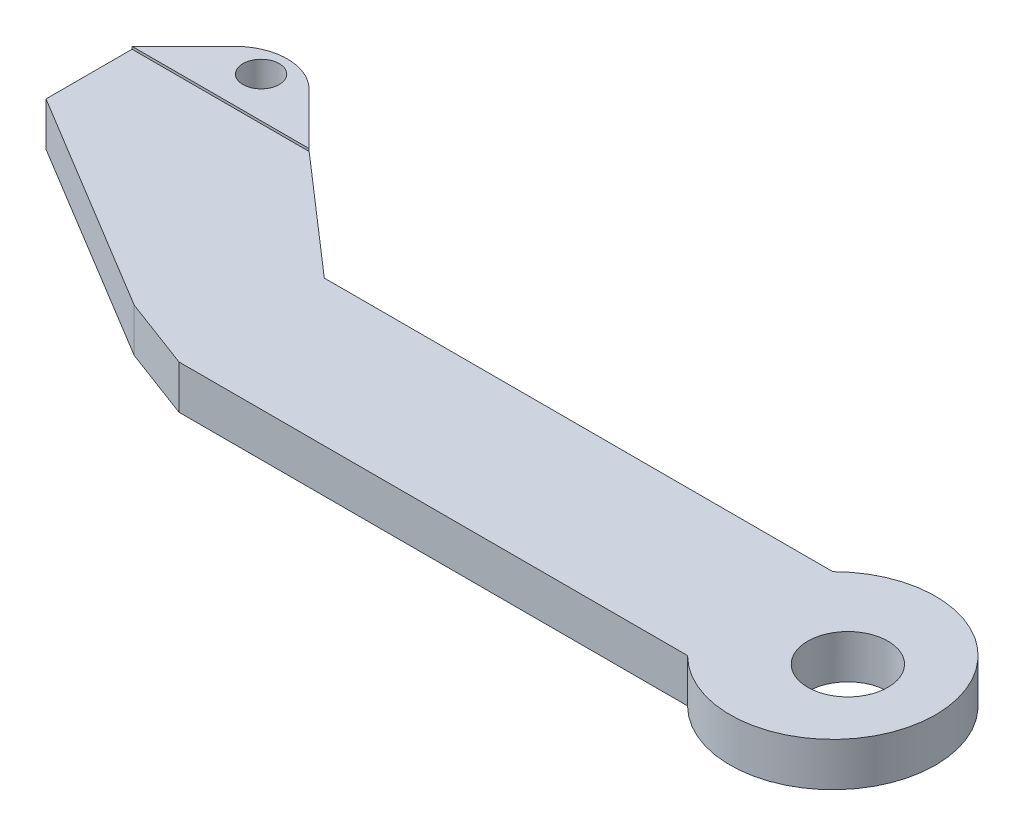
from build123d import *

# Parameters (mm, degrees)
BOSS_EXTRUDE1_DEPTH = 6
SKETCH2_R           = 5.5179
CUT_EXTRUDE1_DEPTH  = 6.35
SKETCH4_R           = 2.5
BOSS_EXTRUDE2_DEPTH = 6.35


with BuildPart() as part:
    # Sketch1 → Boss-Extrude1 (new body)
    with BuildSketch(Plane(origin=(0, 0, 0), x_dir=(1, 0, 0), z_dir=(0, 1, 0))):
        with BuildLine():
            Line((0, 0), (70, 0))
            ThreePointArc((70, 0), (94.142135624, 10), (70, 20))
            Line((70, 20), (0, 20))
            Line((0, 20), (-16.12909928, 34.043913387))
            Line((-16.12909928, 34.043913387), (-40.507954262, 34.043913387))
            Line((-40.507954262, 34.043913387), (-40.507954262, 22.199626998))
            Line((-40.507954262, 22.199626998), (-9.850111043, 3.6873826))
            Line((-9.850111043, 3.6873826), (0, 0))
        make_face()
    extrude(amount=BOSS_EXTRUDE1_DEPTH)

    # Sketch2 → Cut-Extrude1 (cut)
    with BuildSketch(Plane(origin=(0, 6, 0), x_dir=(1, 0, 0), z_dir=(0, 1, 0))):
        with Locations((82.071067812, 10)):
            Circle(SKETCH2_R)
    extrude(amount=-CUT_EXTRUDE1_DEPTH, mode=Mode.SUBTRACT)

    # Sketch4 → Boss-Extrude2 (add)
    with BuildSketch(Plane(origin=(0, 0, 0), x_dir=(1, 0, 0), z_dir=(0, 1, 0))):
        with BuildLine():
            Line((-16.12909928, 34.043913387), (-23.200167092, 41.114981199))
            ThreePointArc((-23.200167092, 41.114981199), (-28.318526771, 43.235075195), (-33.436886451, 41.114981199))
            Line((-33.436886451, 41.114981199), (-40.507954262, 34.043913387))
            Line((-40.507954262, 34.043913387), (-16.12909928, 34.043913387))
        make_face()
        with Locations((-28.318526771, 39.615848358)):
            Circle(SKETCH4_R, mode=Mode.SUBTRACT)
    extrude(amount=BOSS_EXTRUDE2_DEPTH)


solid = part.part
